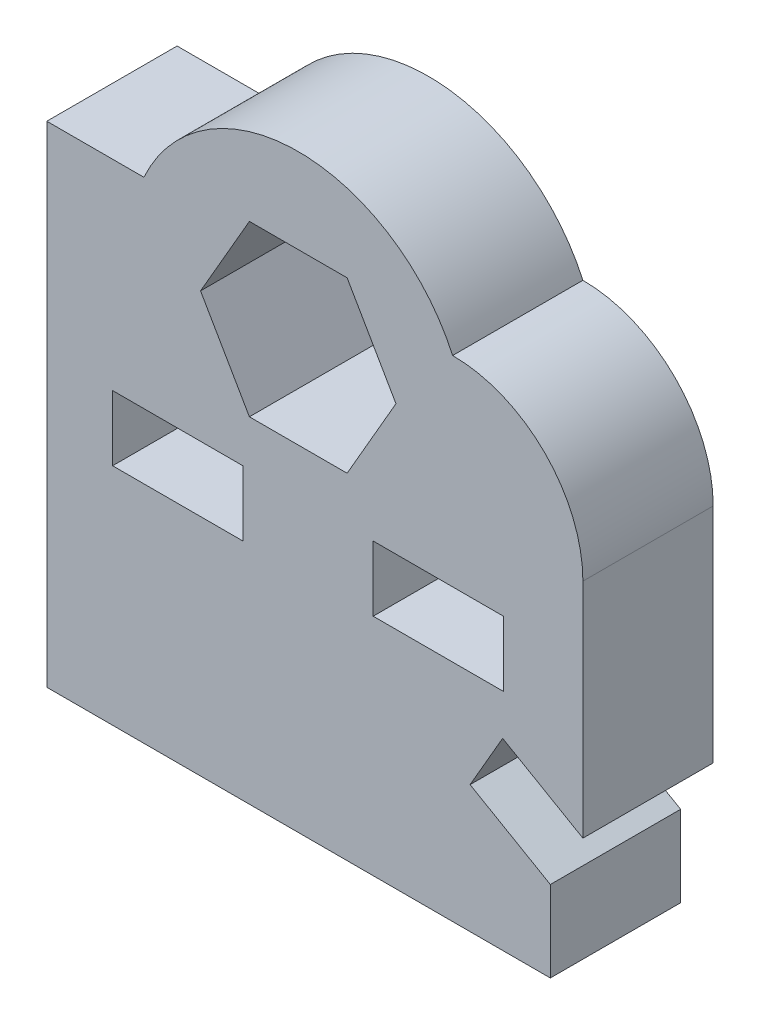
from build123d import *

# Parameters (mm, degrees)
SKETCH1_W           = 4
SKETCH1_H           = 2
BOSS_EXTRUDE1_DEPTH = 4


with BuildPart() as part:
    # Sketch1 → Boss-Extrude1 (new body)
    with BuildSketch(Plane.XY):
        with BuildLine():
            Line((14.475572066, 6), (15.475572066, 7.732050808))
            Line((15.475572066, 7.732050808), (17.939673681, 6.309401077))
            Line((17.939673681, 6.309401077), (17.939673681, 13.142551265))
            ThreePointArc((17.939673681, 13.142551265), (16.768100806, 15.97097839), (13.939673681, 17.142551265))
            ThreePointArc((13.939673681, 17.142551265), (9.2, 20.197069168), (4.460326319, 17.142551265))
            Line((4.460326319, 17.142551265), (1.48, 17.142551265))
            Line((1.48, 17.142551265), (1.48, 2.09107808))
            Line((1.48, 2.09107808), (16.939673681, 2.09107808))
            Line((16.939673681, 2.09107808), (16.939673681, 4.577350269))
            Line((16.939673681, 4.577350269), (14.475572066, 6))
        make_face()
        with Locations((5.5, 9.99107808)):
            Rectangle(SKETCH1_W, SKETCH1_H, mode=Mode.SUBTRACT)
        with Locations((13.5, 9.99107808)):
            Rectangle(SKETCH1_W, SKETCH1_H, mode=Mode.SUBTRACT)
        Polygon((6.2, 14.99107808), (7.7, 12.393001869), (10.7, 12.393001869), (12.2, 14.99107808), (10.7, 17.589154291), (7.7, 17.589154291), align=None, mode=Mode.SUBTRACT)
    extrude(amount=BOSS_EXTRUDE1_DEPTH)


solid = part.part
